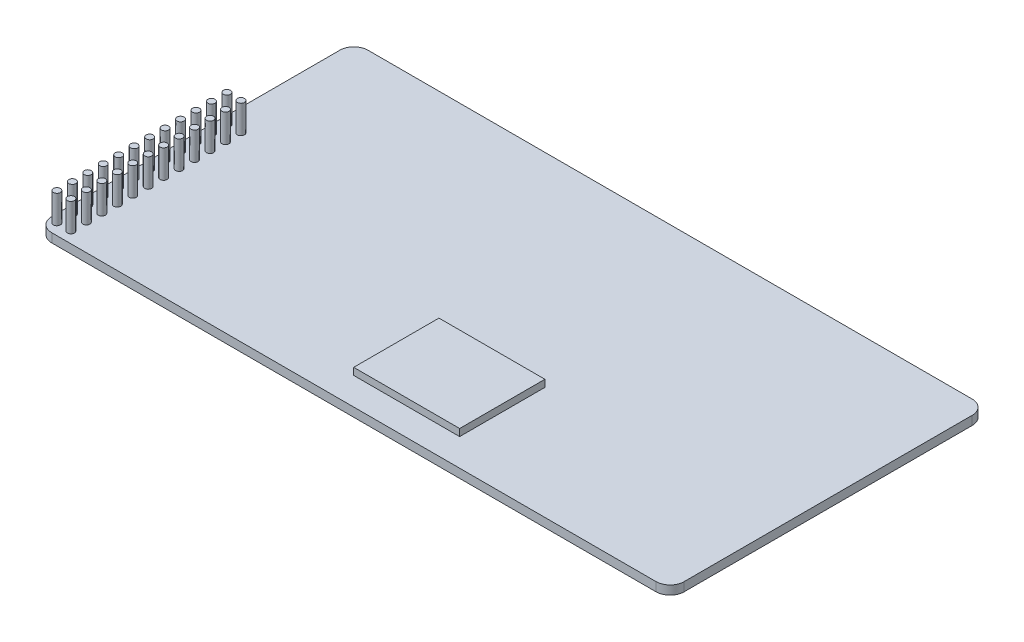
from build123d import *

# Parameters (mm, degrees)
EXTRUDE1_DEPTH    = 1.6002
FILLET1_R         = 2.54
SKETCH2_W         = 19.150793651
SKETCH2_H         = 15.411289565
EXTRUDE2_DEPTH    = 1.27
SKETCH3_R         = 0.635
EXTRUDE3_DEPTH    = 5.08
EXTRUDE3_2_DEPTH  = 5.08
EXTRUDE3_3_DEPTH  = 5.08
EXTRUDE3_4_DEPTH  = 5.08
EXTRUDE3_5_DEPTH  = 5.08
EXTRUDE3_6_DEPTH  = 5.08
EXTRUDE3_7_DEPTH  = 5.08
EXTRUDE3_8_DEPTH  = 5.08
EXTRUDE3_9_DEPTH  = 5.08
EXTRUDE3_10_DEPTH = 5.08
EXTRUDE3_11_DEPTH = 5.08
EXTRUDE3_12_DEPTH = 5.08
EXTRUDE3_13_DEPTH = 5.08
EXTRUDE3_14_DEPTH = 5.08
EXTRUDE3_15_DEPTH = 5.08
EXTRUDE3_16_DEPTH = 5.08
EXTRUDE3_17_DEPTH = 5.08
EXTRUDE3_18_DEPTH = 5.08
EXTRUDE3_19_DEPTH = 5.08
EXTRUDE3_20_DEPTH = 5.08
EXTRUDE3_21_DEPTH = 5.08
EXTRUDE3_22_DEPTH = 5.08
EXTRUDE3_23_DEPTH = 5.08
EXTRUDE3_24_DEPTH = 5.08


with BuildPart() as part:
    # Sketch1 → Extrude1 (new body)
    with BuildSketch(Plane(origin=(0, 0, 0), x_dir=(1, 0, 0), z_dir=(0, 1, 0))):
        Polygon((-55.88, -28.575), (49.53, -28.575), (57.15, -28.575), (57.15, -22.225), (57.15, 28.575), (-57.15, 28.575), (-57.15, -22.225), (-57.15, -28.575), align=None)
    extrude(amount=EXTRUDE1_DEPTH)

    # Fillet1
    fillet1_edges = [part.edges().sort_by_distance(p)[0] for p in [
        (57.15, 0.8001, 28.575),
        (-57.15, 0.8001, 28.575),
        (-57.15, 0.8001, -28.575),
        (57.15, 0.8001, -28.575),
    ]]
    fillet(fillet1_edges, radius=FILLET1_R)


with BuildPart() as body_2:
    # Sketch2 → Extrude2 (new body)
    with BuildSketch(Plane(origin=(0, 1.6002, 0), x_dir=(1, 0, 0), z_dir=(0, 1, 0))):
        with Locations((4.589391378, -15.921221941)):
            Rectangle(SKETCH2_W, SKETCH2_H)
    extrude(amount=EXTRUDE2_DEPTH)


with BuildPart() as body_3:
    # Sketch3 → Extrude3 (new body)
    with BuildSketch(Plane(origin=(0, 1.6002, 0), x_dir=(1, 0, 0), z_dir=(0, 1, 0))):
        with Locations(Location((-55.687305366, 4.155645404, 0), (0, 0, 270))):  # turned: the seam where the file's is
            Circle(SKETCH3_R)
    extrude(amount=EXTRUDE3_DEPTH)


with BuildPart() as body_4:
    # Sketch3 → Extrude3 2 (new body)
    with BuildSketch(Plane(origin=(0, 1.6002, 0), x_dir=(1, 0, 0), z_dir=(0, 1, 0))):
        with Locations(Location((-53.147305366, 4.155645404, 0), (0, 0, 270))):  # turned: the seam where the file's is
            Circle(SKETCH3_R)
    extrude(amount=EXTRUDE3_2_DEPTH)


with BuildPart() as body_5:
    # Sketch3 → Extrude3 3 (new body)
    with BuildSketch(Plane(origin=(0, 1.6002, 0), x_dir=(1, 0, 0), z_dir=(0, 1, 0))):
        with Locations(Location((-55.687305366, 1.361645404, 0), (0, 0, 270))):  # turned: the seam where the file's is
            Circle(SKETCH3_R)
    extrude(amount=EXTRUDE3_3_DEPTH)


with BuildPart() as body_6:
    # Sketch3 → Extrude3 4 (new body)
    with BuildSketch(Plane(origin=(0, 1.6002, 0), x_dir=(1, 0, 0), z_dir=(0, 1, 0))):
        with Locations(Location((-53.147305366, 1.361645404, 0), (0, 0, 270))):  # turned: the seam where the file's is
            Circle(SKETCH3_R)
    extrude(amount=EXTRUDE3_4_DEPTH)


with BuildPart() as body_7:
    # Sketch3 → Extrude3 5 (new body)
    with BuildSketch(Plane(origin=(0, 1.6002, 0), x_dir=(1, 0, 0), z_dir=(0, 1, 0))):
        with Locations(Location((-55.687305366, -1.432354596, 0), (0, 0, 270))):  # turned: the seam where the file's is
            Circle(SKETCH3_R)
    extrude(amount=EXTRUDE3_5_DEPTH)


with BuildPart() as body_8:
    # Sketch3 → Extrude3 6 (new body)
    with BuildSketch(Plane(origin=(0, 1.6002, 0), x_dir=(1, 0, 0), z_dir=(0, 1, 0))):
        with Locations(Location((-53.147305366, -1.432354596, 0), (0, 0, 270))):  # turned: the seam where the file's is
            Circle(SKETCH3_R)
    extrude(amount=EXTRUDE3_6_DEPTH)


with BuildPart() as body_9:
    # Sketch3 → Extrude3 7 (new body)
    with BuildSketch(Plane(origin=(0, 1.6002, 0), x_dir=(1, 0, 0), z_dir=(0, 1, 0))):
        with Locations(Location((-55.687305366, -4.226354596, 0), (0, 0, 270))):  # turned: the seam where the file's is
            Circle(SKETCH3_R)
    extrude(amount=EXTRUDE3_7_DEPTH)


with BuildPart() as body_10:
    # Sketch3 → Extrude3 8 (new body)
    with BuildSketch(Plane(origin=(0, 1.6002, 0), x_dir=(1, 0, 0), z_dir=(0, 1, 0))):
        with Locations(Location((-53.147305366, -4.226354596, 0), (0, 0, 270))):  # turned: the seam where the file's is
            Circle(SKETCH3_R)
    extrude(amount=EXTRUDE3_8_DEPTH)


with BuildPart() as body_11:
    # Sketch3 → Extrude3 9 (new body)
    with BuildSketch(Plane(origin=(0, 1.6002, 0), x_dir=(1, 0, 0), z_dir=(0, 1, 0))):
        with Locations(Location((-55.687305366, -7.020354596, 0), (0, 0, 270))):  # turned: the seam where the file's is
            Circle(SKETCH3_R)
    extrude(amount=EXTRUDE3_9_DEPTH)


with BuildPart() as body_12:
    # Sketch3 → Extrude3 10 (new body)
    with BuildSketch(Plane(origin=(0, 1.6002, 0), x_dir=(1, 0, 0), z_dir=(0, 1, 0))):
        with Locations(Location((-53.147305366, -7.020354596, 0), (0, 0, 270))):  # turned: the seam where the file's is
            Circle(SKETCH3_R)
    extrude(amount=EXTRUDE3_10_DEPTH)


with BuildPart() as body_13:
    # Sketch3 → Extrude3 11 (new body)
    with BuildSketch(Plane(origin=(0, 1.6002, 0), x_dir=(1, 0, 0), z_dir=(0, 1, 0))):
        with Locations(Location((-55.687305366, -9.814354596, 0), (0, 0, 270))):  # turned: the seam where the file's is
            Circle(SKETCH3_R)
    extrude(amount=EXTRUDE3_11_DEPTH)


with BuildPart() as body_14:
    # Sketch3 → Extrude3 12 (new body)
    with BuildSketch(Plane(origin=(0, 1.6002, 0), x_dir=(1, 0, 0), z_dir=(0, 1, 0))):
        with Locations(Location((-53.147305366, -9.814354596, 0), (0, 0, 270))):  # turned: the seam where the file's is
            Circle(SKETCH3_R)
    extrude(amount=EXTRUDE3_12_DEPTH)


with BuildPart() as body_15:
    # Sketch3 → Extrude3 13 (new body)
    with BuildSketch(Plane(origin=(0, 1.6002, 0), x_dir=(1, 0, 0), z_dir=(0, 1, 0))):
        with Locations(Location((-55.687305366, -12.608354596, 0), (0, 0, 270))):  # turned: the seam where the file's is
            Circle(SKETCH3_R)
    extrude(amount=EXTRUDE3_13_DEPTH)


with BuildPart() as body_16:
    # Sketch3 → Extrude3 14 (new body)
    with BuildSketch(Plane(origin=(0, 1.6002, 0), x_dir=(1, 0, 0), z_dir=(0, 1, 0))):
        with Locations(Location((-53.147305366, -12.608354596, 0), (0, 0, 270))):  # turned: the seam where the file's is
            Circle(SKETCH3_R)
    extrude(amount=EXTRUDE3_14_DEPTH)


with BuildPart() as body_17:
    # Sketch3 → Extrude3 15 (new body)
    with BuildSketch(Plane(origin=(0, 1.6002, 0), x_dir=(1, 0, 0), z_dir=(0, 1, 0))):
        with Locations(Location((-55.687305366, -15.402354596, 0), (0, 0, 270))):  # turned: the seam where the file's is
            Circle(SKETCH3_R)
    extrude(amount=EXTRUDE3_15_DEPTH)


with BuildPart() as body_18:
    # Sketch3 → Extrude3 16 (new body)
    with BuildSketch(Plane(origin=(0, 1.6002, 0), x_dir=(1, 0, 0), z_dir=(0, 1, 0))):
        with Locations(Location((-53.147305366, -15.402354596, 0), (0, 0, 270))):  # turned: the seam where the file's is
            Circle(SKETCH3_R)
    extrude(amount=EXTRUDE3_16_DEPTH)


with BuildPart() as body_19:
    # Sketch3 → Extrude3 17 (new body)
    with BuildSketch(Plane(origin=(0, 1.6002, 0), x_dir=(1, 0, 0), z_dir=(0, 1, 0))):
        with Locations(Location((-55.687305366, -18.196354596, 0), (0, 0, 270))):  # turned: the seam where the file's is
            Circle(SKETCH3_R)
    extrude(amount=EXTRUDE3_17_DEPTH)


with BuildPart() as body_20:
    # Sketch3 → Extrude3 18 (new body)
    with BuildSketch(Plane(origin=(0, 1.6002, 0), x_dir=(1, 0, 0), z_dir=(0, 1, 0))):
        with Locations(Location((-53.147305366, -18.196354596, 0), (0, 0, 270))):  # turned: the seam where the file's is
            Circle(SKETCH3_R)
    extrude(amount=EXTRUDE3_18_DEPTH)


with BuildPart() as body_21:
    # Sketch3 → Extrude3 19 (new body)
    with BuildSketch(Plane(origin=(0, 1.6002, 0), x_dir=(1, 0, 0), z_dir=(0, 1, 0))):
        with Locations(Location((-55.687305366, -20.990354596, 0), (0, 0, 270))):  # turned: the seam where the file's is
            Circle(SKETCH3_R)
    extrude(amount=EXTRUDE3_19_DEPTH)


with BuildPart() as body_22:
    # Sketch3 → Extrude3 20 (new body)
    with BuildSketch(Plane(origin=(0, 1.6002, 0), x_dir=(1, 0, 0), z_dir=(0, 1, 0))):
        with Locations(Location((-53.147305366, -20.990354596, 0), (0, 0, 270))):  # turned: the seam where the file's is
            Circle(SKETCH3_R)
    extrude(amount=EXTRUDE3_20_DEPTH)


with BuildPart() as body_23:
    # Sketch3 → Extrude3 21 (new body)
    with BuildSketch(Plane(origin=(0, 1.6002, 0), x_dir=(1, 0, 0), z_dir=(0, 1, 0))):
        with Locations(Location((-55.687305366, -23.784354596, 0), (0, 0, 270))):  # turned: the seam where the file's is
            Circle(SKETCH3_R)
    extrude(amount=EXTRUDE3_21_DEPTH)


with BuildPart() as body_24:
    # Sketch3 → Extrude3 22 (new body)
    with BuildSketch(Plane(origin=(0, 1.6002, 0), x_dir=(1, 0, 0), z_dir=(0, 1, 0))):
        with Locations(Location((-53.147305366, -23.784354596, 0), (0, 0, 270))):  # turned: the seam where the file's is
            Circle(SKETCH3_R)
    extrude(amount=EXTRUDE3_22_DEPTH)


with BuildPart() as body_25:
    # Sketch3 → Extrude3 23 (new body)
    with BuildSketch(Plane(origin=(0, 1.6002, 0), x_dir=(1, 0, 0), z_dir=(0, 1, 0))):
        with Locations(Location((-55.687305366, -26.578354596, 0), (0, 0, 270))):  # turned: the seam where the file's is
            Circle(SKETCH3_R)
    extrude(amount=EXTRUDE3_23_DEPTH)


with BuildPart() as body_26:
    # Sketch3 → Extrude3 24 (new body)
    with BuildSketch(Plane(origin=(0, 1.6002, 0), x_dir=(1, 0, 0), z_dir=(0, 1, 0))):
        with Locations(Location((-53.147305366, -26.578354596, 0), (0, 0, 270))):  # turned: the seam where the file's is
            Circle(SKETCH3_R)
    extrude(amount=EXTRUDE3_24_DEPTH)


solid = Compound([part.part, body_2.part, body_3.part, body_4.part, body_5.part, body_6.part, body_7.part, body_8.part, body_9.part, body_10.part, body_11.part, body_12.part, body_13.part, body_14.part, body_15.part, body_16.part, body_17.part, body_18.part, body_19.part, body_20.part, body_21.part, body_22.part, body_23.part, body_24.part, body_25.part, body_26.part])
